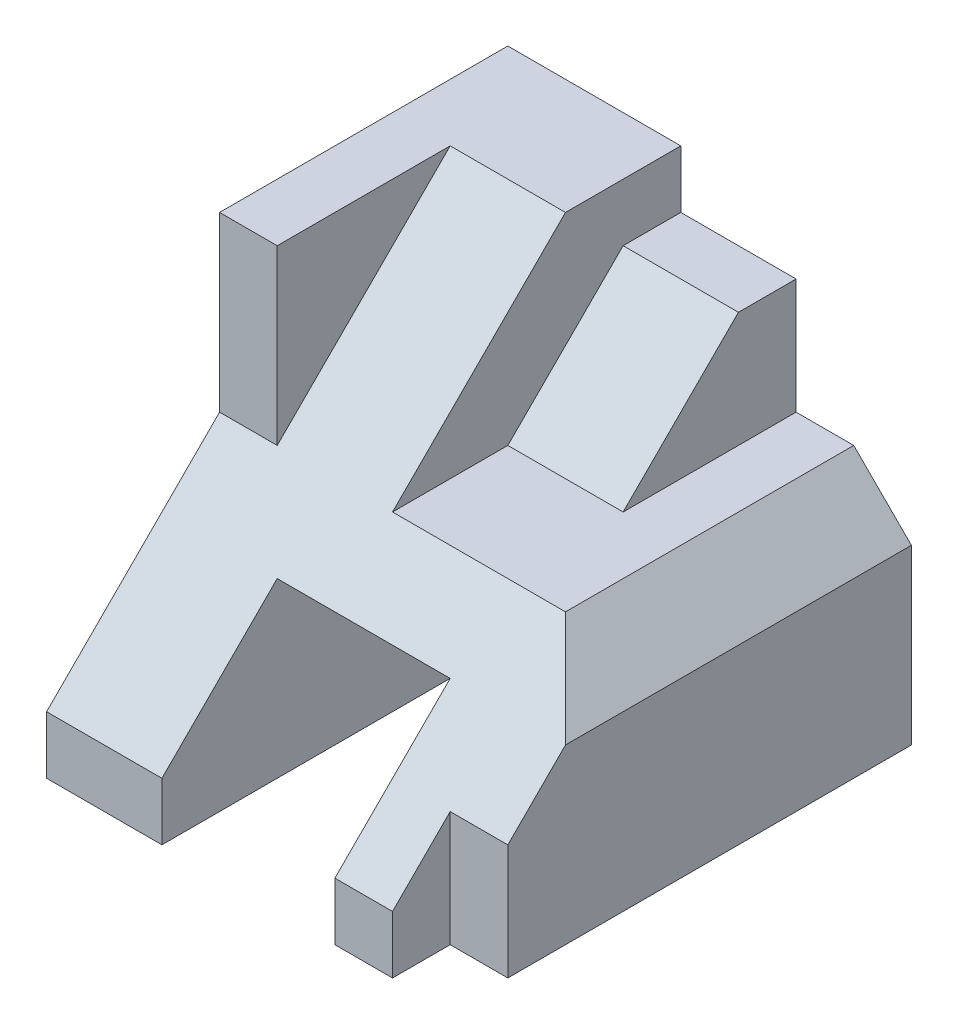
from build123d import *

# Parameters (mm, degrees)
SKETCH1_W           = 7
SKETCH1_H           = 7
BOSS_EXTRUDE1_DEPTH = 8
SKETCH2_W           = 3
SKETCH2_H           = 3
CUT_EXTRUDE1_DEPTH  = 9
CUT_EXTRUDE2_DEPTH  = 6
CUT_EXTRUDE3_DEPTH  = 6
SKETCH5_W           = 1
SKETCH5_H           = 2
CUT_EXTRUDE4_DEPTH  = 1
CUT_EXTRUDE5_DEPTH  = 4
SKETCH7_W           = 2
SKETCH7_H           = 3
CUT_EXTRUDE6_DEPTH  = 2
CUT_EXTRUDE7_DEPTH  = 6


with BuildPart() as part:
    # Sketch1 → Boss-Extrude1 (new body)
    with BuildSketch(Plane.XY):
        Rectangle(SKETCH1_W, SKETCH1_H)
    extrude(amount=BOSS_EXTRUDE1_DEPTH)

    # Sketch2 → Cut-Extrude1 (cut, through all)
    with BuildSketch(Plane.XY.offset(8)):
        with Locations((0, -2)):
            Rectangle(SKETCH2_W, SKETCH2_H)
    extrude(amount=-CUT_EXTRUDE1_DEPTH, mode=Mode.SUBTRACT)

    # Sketch3 → Cut-Extrude2 (cut)
    with BuildSketch(Plane(origin=(3.5, 0, 0), x_dir=(0, 0, -1), z_dir=(1, 0, 0))):
        Polygon((-8, -2.5), (-2, 3.5), (-8, 3.5), align=None)
    extrude(amount=-CUT_EXTRUDE2_DEPTH, mode=Mode.SUBTRACT)

    # Sketch4 → Cut-Extrude3 (cut)
    with BuildSketch(Plane(origin=(-2.5, 0, 0), x_dir=(0, 0, -1), z_dir=(1, 0, 0))):
        Polygon((-5, 3.5), (-5, 0.5), (-8, -2.5), (-8, 3.5), align=None)
    extrude(amount=-CUT_EXTRUDE3_DEPTH, mode=Mode.SUBTRACT)

    # Sketch5 → Cut-Extrude4 (cut)
    with BuildSketch(Plane(origin=(3.5, 0, 0), x_dir=(0, 0, -1), z_dir=(1, 0, 0))):
        with Locations((-7.5, -2.5)):
            Rectangle(SKETCH5_W, SKETCH5_H)
    extrude(amount=-CUT_EXTRUDE4_DEPTH, mode=Mode.SUBTRACT)

    # Sketch6 → Cut-Extrude5 (cut)
    with BuildSketch(Plane(origin=(3.5, 0, 0), x_dir=(0, 0, -1), z_dir=(1, 0, 0))):
        Polygon((0, 3.5), (-2, 3.5), (-5, 0.5), (-3, 0.5), (-1, 2.5), (0, 2.5), align=None)
    extrude(amount=-CUT_EXTRUDE5_DEPTH, mode=Mode.SUBTRACT)

    # Sketch7 → Cut-Extrude6 (cut)
    with BuildSketch(Plane(origin=(0, 2.5, 0), x_dir=(1, 0, 0), z_dir=(0, 1, 0))):
        with Locations((2.5, -1.5)):
            Rectangle(SKETCH7_W, SKETCH7_H)
    extrude(amount=-CUT_EXTRUDE6_DEPTH, mode=Mode.SUBTRACT)

    # Sketch8 → Cut-Extrude7 (cut)
    with BuildSketch(Plane(origin=(0, 0, 0), x_dir=(-1, 0, 0), z_dir=(0, 0, -1))):
        Polygon((-2.5, 0.5), (-3.5, -0.5), (-3.5, 0.5), align=None)
    extrude(amount=-CUT_EXTRUDE7_DEPTH, mode=Mode.SUBTRACT)


solid = part.part
